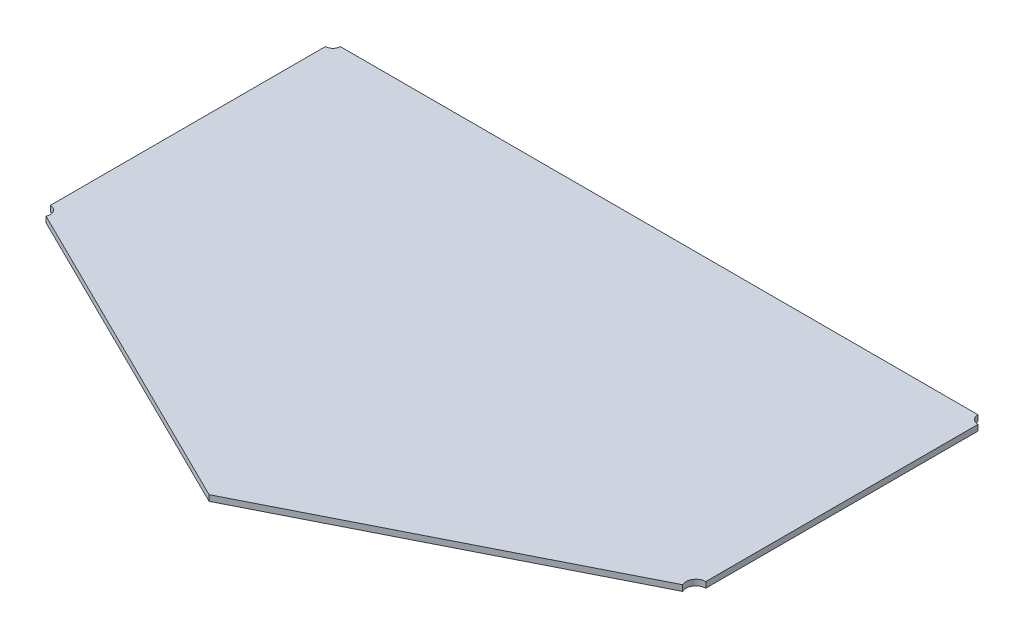
from build123d import *

# Parameters (mm, degrees)
BOSS_EXTRUDE1_DEPTH = 4
SKETCH3_R           = 5.470416759
SKETCH3_R_2         = 5.136398205
SKETCH3_R_3         = 5.743645838
SKETCH3_R_4         = 6.779267961
CUT_EXTRUDE2_DEPTH  = 85


with BuildPart() as part:
    # Sketch1 → Boss-Extrude1 (new body)
    with BuildSketch(Plane(origin=(0, 0, 0), x_dir=(1, 0, 0), z_dir=(0, 1, 0))):
        with BuildLine():
            Line((-234.498829852, -2.772290193), (-7.346998412, -115.1588183))
            Line((-7.346998412, -115.1588183), (215.490107836, -2.772308919))
            ThreePointArc((215.490107836, -2.772308919), (215.494120314, -2.768622763), (215.495604699, -2.763380215))
            Line((215.495604699, -2.763380215), (215.495604699, 197.217709807))
            ThreePointArc((215.495604699, 197.217709807), (215.492675767, 197.224780875), (215.485604699, 197.227709807))
            Line((215.485604699, 197.227709807), (-234.494395301, 197.227709807))
            ThreePointArc((-234.494395301, 197.227709807), (-234.501466368, 197.224780875), (-234.504395301, 197.217709807))
            Line((-234.504395301, 197.217709807), (-234.504395301, -2.763327228))
            ThreePointArc((-234.504395301, -2.763327228), (-234.502890756, -2.768602381), (-234.498829852, -2.772290193))
        make_face()
    extrude(amount=BOSS_EXTRUDE1_DEPTH)

    # Sketch3 → Cut-Extrude2 (cut)
    with BuildSketch(Plane(origin=(0, 4, 0), x_dir=(1, 0, 0), z_dir=(0, 1, 0))):
        with Locations((-234.494395301, -2.763327228)):
            Circle(SKETCH3_R)
        with Locations((-234.494395301, 197.217709807)):
            Circle(SKETCH3_R_2)
        with Locations((215.485604699, 197.217709807)):
            Circle(SKETCH3_R_3)
        with Locations((215.485604699, -2.763380215)):
            Circle(SKETCH3_R_4)
    extrude(amount=-CUT_EXTRUDE2_DEPTH, mode=Mode.SUBTRACT)


solid = part.part
